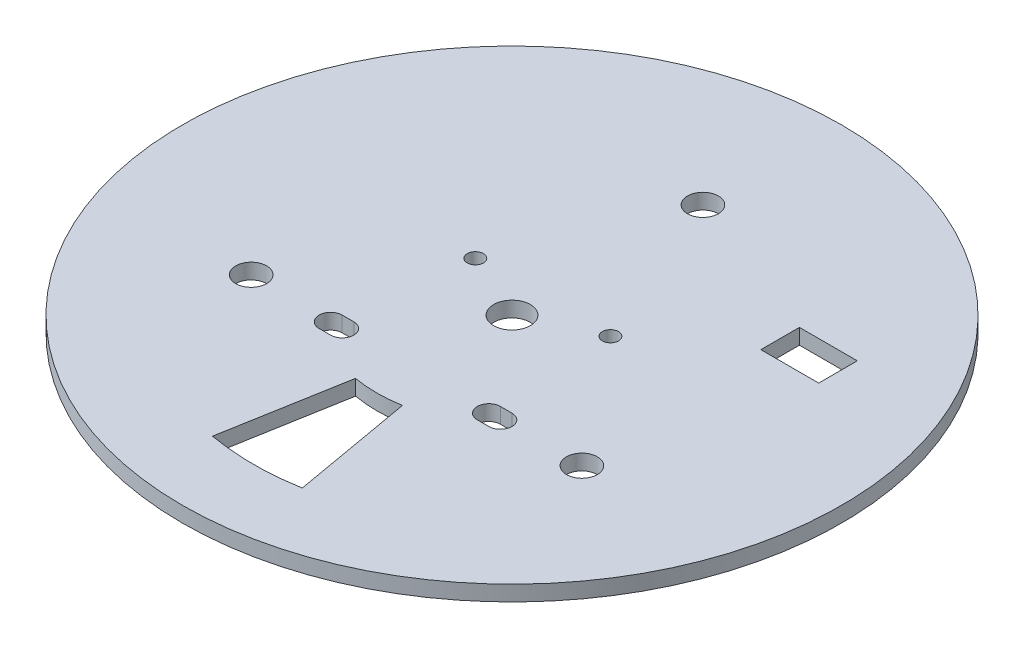
from build123d import *

# Parameters (mm, degrees)
ESBO_O1_R                = 85.4
RESSALTO_EXTRUS_O1_DEPTH = 4
CORTE_EXTRUS_O2_DEPTH    = 5
ESBO_O4_R                = 4
CORTE_EXTRUS_O3_DEPTH    = 5
ESBO_O5_R                = 4.75
CORTE_EXTRUS_O4_DEPTH    = 5
ESBO_O7_R                = 2.1
CORTE_EXTRUS_O5_DEPTH    = 5
CORTE_EXTRUS_O6_REACH    = 6
ESBO_O8_W                = 15
ESBO_O8_H                = 10


with BuildPart() as part:
    # Esboço1 → Ressalto-extrusão1 (new body)
    with BuildSketch(Plane(origin=(0, 0, 0), x_dir=(1, 0, 0), z_dir=(0, 1, 0))):
        Circle(ESBO_O1_R)
    extrude(amount=RESSALTO_EXTRUS_O1_DEPTH)

    # Esboço3 → Corte-extrusão2 (cut, through all)
    with BuildSketch(Plane.XZ):
        with BuildLine():
            Line((6.077686218, 34.468271355), (11.634427904, 65.982119452))
            ThreePointArc((11.634427904, 65.982119452), (0, 67), (-11.634427904, 65.982119452))
            Line((-11.634427904, 65.982119452), (-6.077686218, 34.468271355))
            ThreePointArc((-6.077686218, 34.468271355), (0, 35), (6.077686218, 34.468271355))
        make_face()
    extrude(amount=-CORTE_EXTRUS_O2_DEPTH, mode=Mode.SUBTRACT)

    # Esboço4 → Corte-extrusão3 (cut, through all)
    with BuildSketch(Plane(origin=(0, 4, 0), x_dir=(1, 0, 0), z_dir=(0, 1, 0))):
        with Locations((42.850936979, -24.74)):
            Circle(ESBO_O4_R)
        with Locations((0, 49.48)):
            Circle(ESBO_O4_R)
        with Locations((-42.850936979, -24.74)):
            Circle(ESBO_O4_R)
    extrude(amount=-CORTE_EXTRUS_O3_DEPTH, mode=Mode.SUBTRACT)

    # Esboço5 → Corte-extrusão4 (cut, through all)
    with BuildSketch(Plane.XZ):
        Circle(ESBO_O5_R)
    extrude(amount=-CORTE_EXTRUS_O4_DEPTH, mode=Mode.SUBTRACT)

    # Esboço7 → Corte-extrusão5 (cut, through all)
    with BuildSketch(Plane(origin=(0, 4, 0), x_dir=(1, 0, 0), z_dir=(0, 1, 0))):
        with Locations((-17.5, 8)):
            Circle(ESBO_O7_R)
        with Locations((17.5, 8)):
            Circle(ESBO_O7_R)
        with BuildLine():
            Line((-22, -22), (-19, -22))
            ThreePointArc((-19, -22), (-16, -25), (-19, -28))
            Line((-19, -28), (-22, -28))
            ThreePointArc((-22, -28), (-25, -25), (-22, -22))
        make_face()
        with BuildLine():
            Line((19, -28), (22, -28))
            ThreePointArc((22, -28), (25, -25), (22, -22))
            Line((22, -22), (19, -22))
            ThreePointArc((19, -22), (16, -25), (19, -28))
        make_face()
    extrude(amount=-CORTE_EXTRUS_O5_DEPTH, mode=Mode.SUBTRACT)

    # Esboço8 → Corte-extrusão6 (cut, up to next)
    with BuildSketch(Plane(origin=(0, 4, 0), x_dir=(1, 0, 0), z_dir=(0, 1, 0)), mode=Mode.PRIVATE) as corte_extrus_o6_sk1:
        with Locations((47.5, 29.48)):
            Rectangle(ESBO_O8_W, ESBO_O8_H)
    corte_extrus_o6_tool1 = extrude(corte_extrus_o6_sk1.sketch, amount=-CORTE_EXTRUS_O6_REACH, mode=Mode.PRIVATE) & part.part
    add(corte_extrus_o6_tool1.solids().sort_by_distance((47.5, 4, -29.48))[0], mode=Mode.SUBTRACT)


solid = part.part
